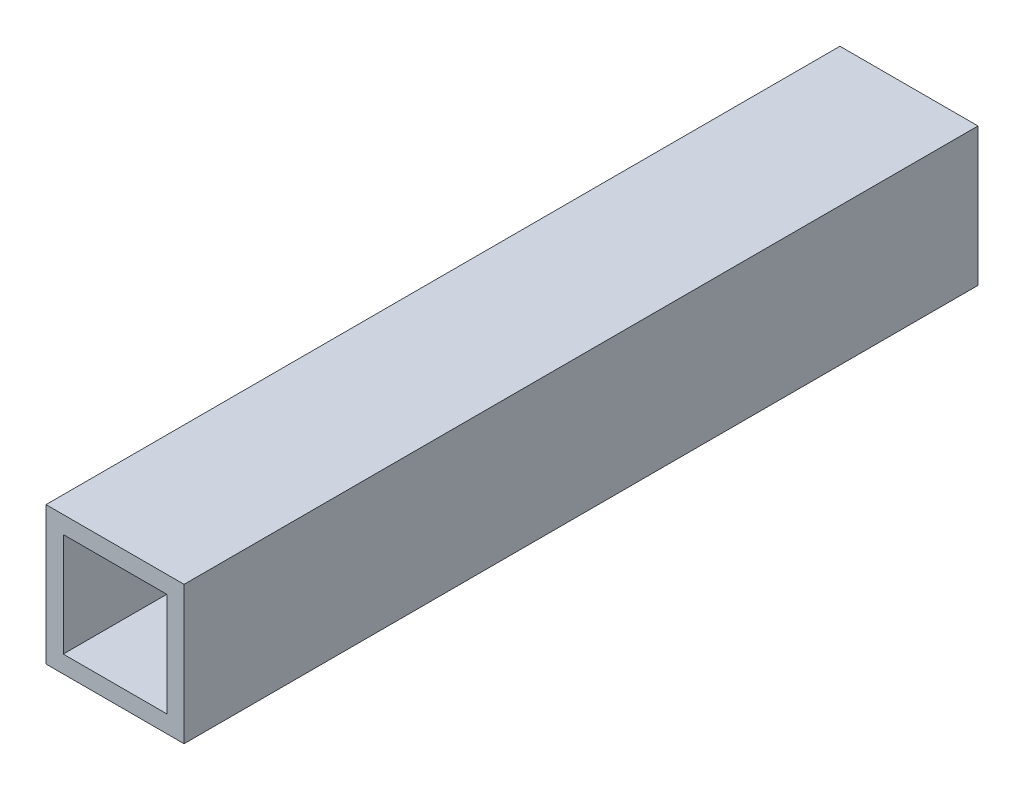
from build123d import *

# Parameters (mm, degrees)
SKETCH1_W           = 40
SKETCH1_H           = 40
SKETCH1_W_2         = 30
SKETCH1_H_2         = 30
BOSS_EXTRUDE5_DEPTH = 230


with BuildPart() as part:
    # Sketch1 → Boss-Extrude5 (new body)
    with BuildSketch(Plane.XY):
        Rectangle(SKETCH1_W, SKETCH1_H)
        Rectangle(SKETCH1_W_2, SKETCH1_H_2, mode=Mode.SUBTRACT)
    extrude(amount=BOSS_EXTRUDE5_DEPTH)


solid = part.part
